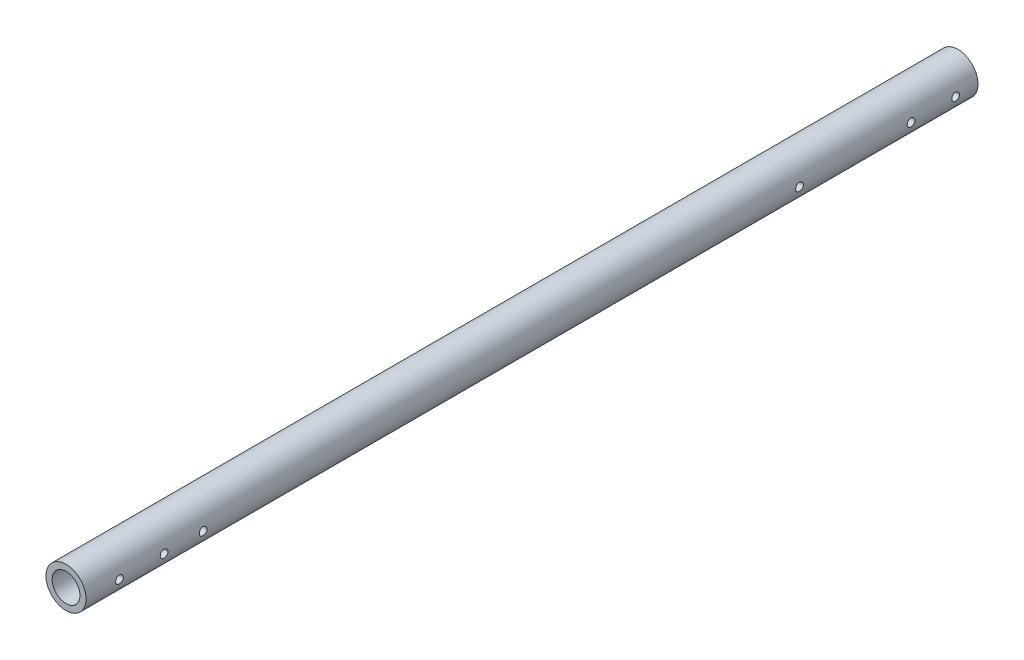
from build123d import *

# Parameters (mm, degrees)
SKETCH_1_R               = 9
SKETCH_1_R_2             = 6.25
EXTRUDE_1_DEPTH          = 400
SKETCH_2_R               = 1.75
CUT_EXTRUDE_1_DEPTH      = 10
CUT_EXTRUDE_1_DEPTH_BACK = 10


with BuildPart() as part:
    # ｽｹｯﾁ1 → ﾎﾞｽ - 押し出し1 (new body)
    with BuildSketch(Plane.XY):
        Circle(SKETCH_1_R)
        Circle(SKETCH_1_R_2, mode=Mode.SUBTRACT)
    extrude(amount=EXTRUDE_1_DEPTH)

    # ｽｹｯﾁ2 → ｶｯﾄ - 押し出し1 (cut, two sides)
    with BuildSketch(Plane(origin=(0, 0, 0), x_dir=(0, 0, -1), z_dir=(1, 0, 0))) as cut_extrude_1_sk:
        with Locations((-10, 0)):
            Circle(SKETCH_2_R)
        with Locations((-385, 0)):
            Circle(SKETCH_2_R)
        with Locations((-30, 0)):
            Circle(SKETCH_2_R)
        with Locations((-365, 0)):
            Circle(SKETCH_2_R)
        with Locations((-347.5, 0)):
            Circle(SKETCH_2_R)
        with Locations((-80, 0)):
            Circle(SKETCH_2_R)
    extrude(amount=CUT_EXTRUDE_1_DEPTH, mode=Mode.SUBTRACT)
    extrude(cut_extrude_1_sk.sketch, amount=-CUT_EXTRUDE_1_DEPTH_BACK, mode=Mode.SUBTRACT)


solid = part.part
